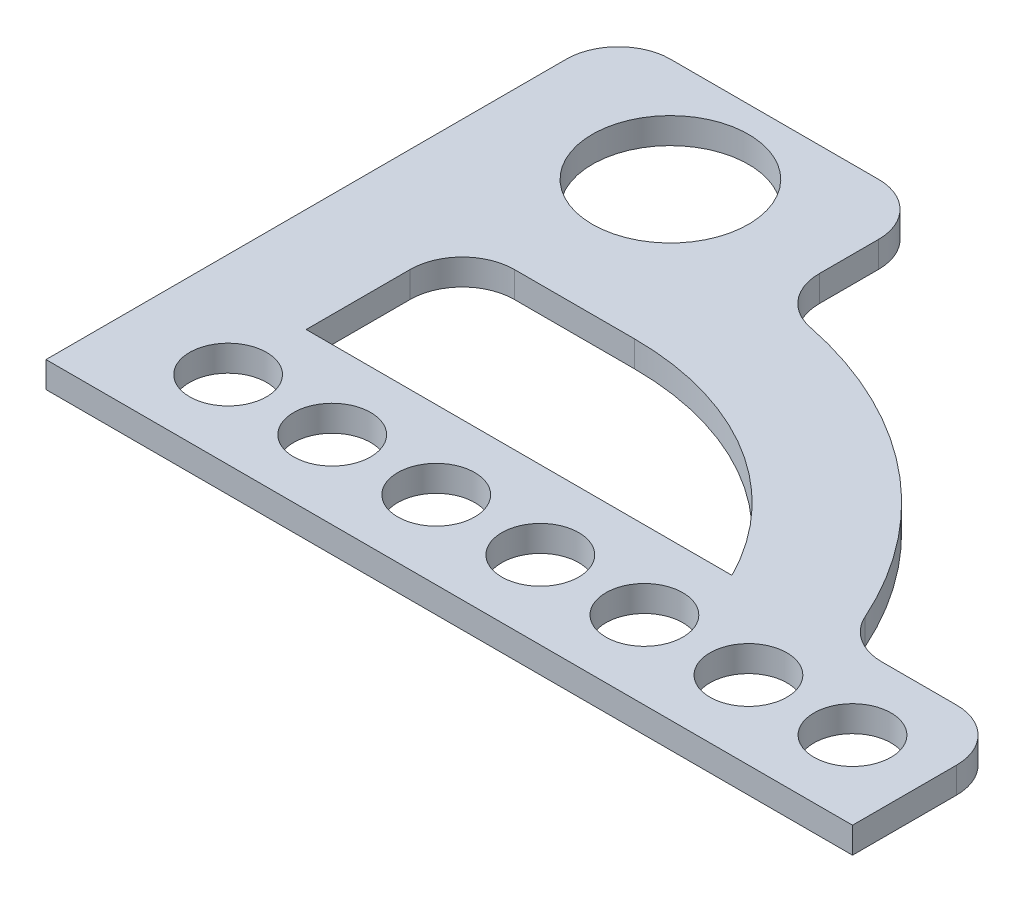
from build123d import *

# Parameters (mm, degrees)
SKETCH1_R           = 15
SKETCH1_R_2         = 7.396823718
BOSS_EXTRUDE1_DEPTH = 5


with BuildPart() as part:
    # Sketch1 → Boss-Extrude1 (new body)
    with BuildSketch(Plane(origin=(0, 0, 0), x_dir=(1, 0, 0), z_dir=(0, 1, 0))):
        with BuildLine():
            Line((155, 0), (155, 20))
            ThreePointArc((155, 20), (152.071067812, 27.071067812), (145, 30))
            Line((145, 30), (130.631756617, 30))
            ThreePointArc((130.631756617, 30), (125.186785887, 31.612372579), (121.497679457, 35.929541251))
            ThreePointArc((121.497679457, 35.929541251), (99.953355799, 63.858544428), (68.011045902, 78.821028806))
            ThreePointArc((68.011045902, 78.821028806), (62.257599178, 82.292315938), (60, 88.621236029))
            Line((60, 88.621236029), (60, 100))
            ThreePointArc((60, 100), (57.071067812, 107.071067812), (50, 110))
            Line((50, 110), (10, 110))
            ThreePointArc((10, 110), (2.928932188, 107.071067812), (0, 100))
            Line((0, 100), (0, 0))
            Line((0, 0), (155, 0))
        make_face()
        with Locations((30, 90)):
            Circle(SKETCH1_R, mode=Mode.SUBTRACT)
        with Locations((20, 15)):
            Circle(SKETCH1_R_2, mode=Mode.SUBTRACT)
        with Locations((40, 15)):
            Circle(SKETCH1_R_2, mode=Mode.SUBTRACT)
        with Locations((60, 15)):
            Circle(SKETCH1_R_2, mode=Mode.SUBTRACT)
        with Locations((80, 15)):
            Circle(SKETCH1_R_2, mode=Mode.SUBTRACT)
        with Locations((100, 15)):
            Circle(SKETCH1_R_2, mode=Mode.SUBTRACT)
        with Locations((120, 15)):
            Circle(SKETCH1_R_2, mode=Mode.SUBTRACT)
        with Locations((140, 15)):
            Circle(SKETCH1_R_2, mode=Mode.SUBTRACT)
        with BuildLine():
            ThreePointArc((30, 60), (22.928932188, 57.071067812), (20, 50))
            Line((20, 50), (20, 30))
            Line((20, 30), (101.830075275, 30))
            ThreePointArc((101.830075275, 30), (81.724911294, 51.898267594), (53.122224807, 60))
            Line((53.122224807, 60), (30, 60))
        make_face(mode=Mode.SUBTRACT)
    extrude(amount=BOSS_EXTRUDE1_DEPTH)


solid = part.part
